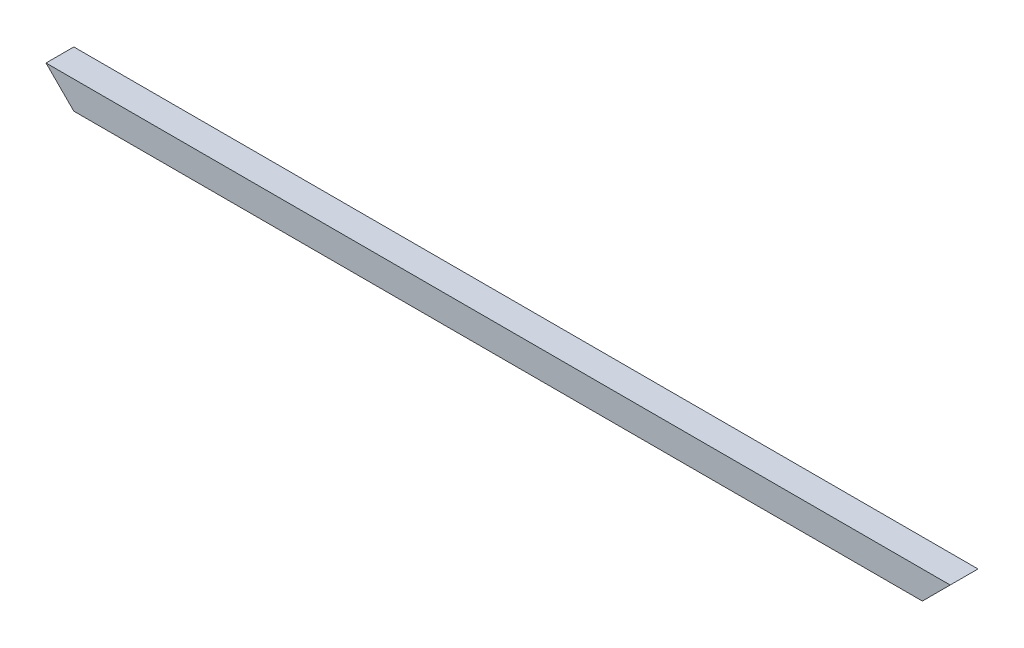
from build123d import *

# Parameters (mm, degrees)
SKETCH1_W               = 20
SKETCH1_H               = 20
SKETCH1_W_2             = 17.6
SKETCH1_H_2             = 17.6
BOSS_EXTRUDE1_DEPTH     = 650
CUT_EXTRUDE1_DEPTH      = 1
CUT_EXTRUDE1_DEPTH_BACK = 21
CUT_EXTRUDE3_DEPTH      = 1
CUT_EXTRUDE3_DEPTH_BACK = 21


with BuildPart() as part:
    # Sketch1 → Boss-Extrude1 (new body)
    with BuildSketch(Plane(origin=(0, 0, 0), x_dir=(0, 0, -1), z_dir=(1, 0, 0))):
        Rectangle(SKETCH1_W, SKETCH1_H)
        Rectangle(SKETCH1_W_2, SKETCH1_H_2, mode=Mode.SUBTRACT)
    extrude(amount=BOSS_EXTRUDE1_DEPTH)

    # Sketch2 → Cut-Extrude1 (cut, two sides)
    with BuildSketch(Plane(origin=(0, 0, -10), x_dir=(-1, 0, 0), z_dir=(0, 0, -1))) as cut_extrude1_sk:
        Polygon((926.744923045, 936.744923045), (0, 10), (-20, -10), (-946.744923045, -936.744923045), (906.744923045, -2790.234769136), (2780.234769136, -916.744923045), align=None)
    extrude(amount=CUT_EXTRUDE1_DEPTH, mode=Mode.SUBTRACT)
    extrude(cut_extrude1_sk.sketch, amount=-CUT_EXTRUDE1_DEPTH_BACK, mode=Mode.SUBTRACT)

    # Sketch3 → Cut-Extrude3 (cut, two sides)
    with BuildSketch(Plane(origin=(0, 0, -10), x_dir=(-1, 0, 0), z_dir=(0, 0, -1))) as cut_extrude3_sk:
        Polygon((-1576.744923045, 936.744923045), (-650, 10), (-630, -10), (296.744923045, -936.744923045), (-1556.744923045, -2790.234769136), (-3430.234769136, -916.744923045), align=None)
    extrude(amount=CUT_EXTRUDE3_DEPTH, mode=Mode.SUBTRACT)
    extrude(cut_extrude3_sk.sketch, amount=-CUT_EXTRUDE3_DEPTH_BACK, mode=Mode.SUBTRACT)


solid = part.part
